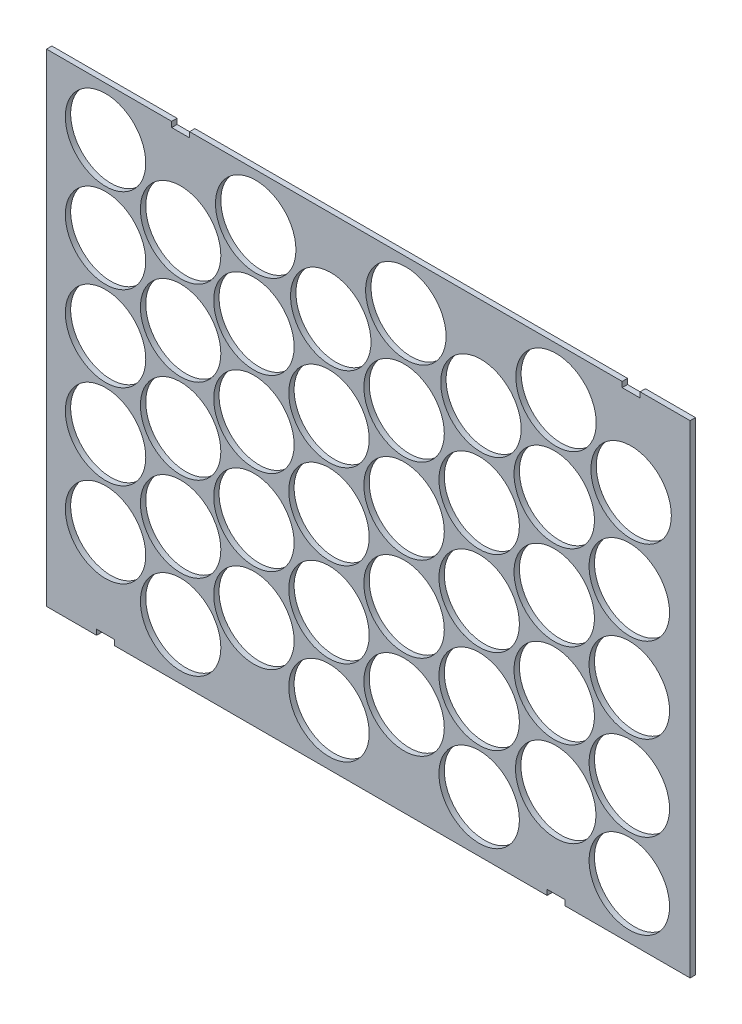
from build123d import *

# Parameters (mm, degrees)
CROQUIS2_R              = 22.5
SALIENTE_EXTRUIR1_DEPTH = 3


with BuildPart() as part:
    # Croquis2 → Saliente-Extruir1 (new body)
    with BuildSketch(Plane.XY):
        Polygon((-78.032689509, 45.481472081), (-8.032689509, 45.481472081), (-8.032689509, 42.481472081), (1.967310491, 42.481472081), (1.967310491, 45.481472081), (243.967310464, 45.494020393), (243.967310464, 45.480623618), (243.967310464, 42.480623618), (253.967310518, 42.480623618), (253.967310518, 45.480623618), (281.967310491, 45.481472081), (281.967310491, -224.518527919), (211.967310491, -224.548290187), (211.967310491, -221.548290187), (201.967310491, -221.548290187), (201.967310491, -224.548290187), (-40.032689509, -224.518544608), (-40.032689509, -221.518544608), (-50.032689509, -221.518544608), (-50.032689509, -224.518544608), (-78.032689509, -224.518527919), align=None)
        with Locations((-45.032689509, 17.981472081)):
            Circle(CROQUIS2_R, mode=Mode.SUBTRACT)
        with Locations((-45.032689509, -29.518527919)):
            Circle(CROQUIS2_R, mode=Mode.SUBTRACT)
        with Locations((-45.032689509, -77.018527919)):
            Circle(CROQUIS2_R, mode=Mode.SUBTRACT)
        with Locations((-45.032689509, -124.518527919)):
            Circle(CROQUIS2_R, mode=Mode.SUBTRACT)
        with Locations((-45.032689509, -172.018527919)):
            Circle(CROQUIS2_R, mode=Mode.SUBTRACT)
        with Locations((-3.032689509, -5.768527919)):
            Circle(CROQUIS2_R, mode=Mode.SUBTRACT)
        with Locations((38.967310491, 17.981472081)):
            Circle(CROQUIS2_R, mode=Mode.SUBTRACT)
        with Locations((80.967310491, -5.768527919)):
            Circle(CROQUIS2_R, mode=Mode.SUBTRACT)
        with Locations((122.967310491, 17.981472081)):
            Circle(CROQUIS2_R, mode=Mode.SUBTRACT)
        with Locations((164.967310491, -5.768527919)):
            Circle(CROQUIS2_R, mode=Mode.SUBTRACT)
        with Locations((-3.032689509, -53.268527919)):
            Circle(CROQUIS2_R, mode=Mode.SUBTRACT)
        with Locations((-3.032689509, -100.768527919)):
            Circle(CROQUIS2_R, mode=Mode.SUBTRACT)
        with Locations((-3.032689509, -148.268527919)):
            Circle(CROQUIS2_R, mode=Mode.SUBTRACT)
        with Locations((-3.032689509, -195.768527919)):
            Circle(CROQUIS2_R, mode=Mode.SUBTRACT)
        with Locations((37.967310491, -29.518527919)):
            Circle(CROQUIS2_R, mode=Mode.SUBTRACT)
        with Locations((37.967310491, -77.018527919)):
            Circle(CROQUIS2_R, mode=Mode.SUBTRACT)
        with Locations((37.967310491, -124.518527919)):
            Circle(CROQUIS2_R, mode=Mode.SUBTRACT)
        with Locations((37.967310491, -172.018527919)):
            Circle(CROQUIS2_R, mode=Mode.SUBTRACT)
        with Locations((79.967310491, -53.268527919)):
            Circle(CROQUIS2_R, mode=Mode.SUBTRACT)
        with Locations((79.967310491, -100.768527919)):
            Circle(CROQUIS2_R, mode=Mode.SUBTRACT)
        with Locations((79.967310491, -148.268527919)):
            Circle(CROQUIS2_R, mode=Mode.SUBTRACT)
        with Locations((79.967310491, -195.768527919)):
            Circle(CROQUIS2_R, mode=Mode.SUBTRACT)
        with Locations((121.967310491, -29.518527919)):
            Circle(CROQUIS2_R, mode=Mode.SUBTRACT)
        with Locations((163.967310491, -53.268527919)):
            Circle(CROQUIS2_R, mode=Mode.SUBTRACT)
        with Locations((121.967310491, -77.018527919)):
            Circle(CROQUIS2_R, mode=Mode.SUBTRACT)
        with Locations((163.967310491, -100.768527919)):
            Circle(CROQUIS2_R, mode=Mode.SUBTRACT)
        with Locations((121.967310491, -124.518527919)):
            Circle(CROQUIS2_R, mode=Mode.SUBTRACT)
        with Locations((121.967310491, -172.018527919)):
            Circle(CROQUIS2_R, mode=Mode.SUBTRACT)
        with Locations((163.967310491, -148.268527919)):
            Circle(CROQUIS2_R, mode=Mode.SUBTRACT)
        with Locations((163.967310491, -195.768527919)):
            Circle(CROQUIS2_R, mode=Mode.SUBTRACT)
        with Locations((206.967310491, 18.071533546)):
            Circle(CROQUIS2_R, mode=Mode.SUBTRACT)
        with Locations((205.967310491, -29.518527919)):
            Circle(CROQUIS2_R, mode=Mode.SUBTRACT)
        with Locations((205.967310491, -77.018527919)):
            Circle(CROQUIS2_R, mode=Mode.SUBTRACT)
        with Locations((205.967310491, -124.518527919)):
            Circle(CROQUIS2_R, mode=Mode.SUBTRACT)
        with Locations((206.796228515, -171.928466454)):
            Circle(CROQUIS2_R, mode=Mode.SUBTRACT)
        with Locations((248.967310491, -5.768527919)):
            Circle(CROQUIS2_R, mode=Mode.SUBTRACT)
        with Locations((247.967310491, -53.268527919)):
            Circle(CROQUIS2_R, mode=Mode.SUBTRACT)
        with Locations((247.967310491, -100.768527919)):
            Circle(CROQUIS2_R, mode=Mode.SUBTRACT)
        with Locations((247.967310491, -148.268527919)):
            Circle(CROQUIS2_R, mode=Mode.SUBTRACT)
        with Locations((247.967310491, -195.768527919)):
            Circle(CROQUIS2_R, mode=Mode.SUBTRACT)
    extrude(amount=SALIENTE_EXTRUIR1_DEPTH)


solid = part.part
